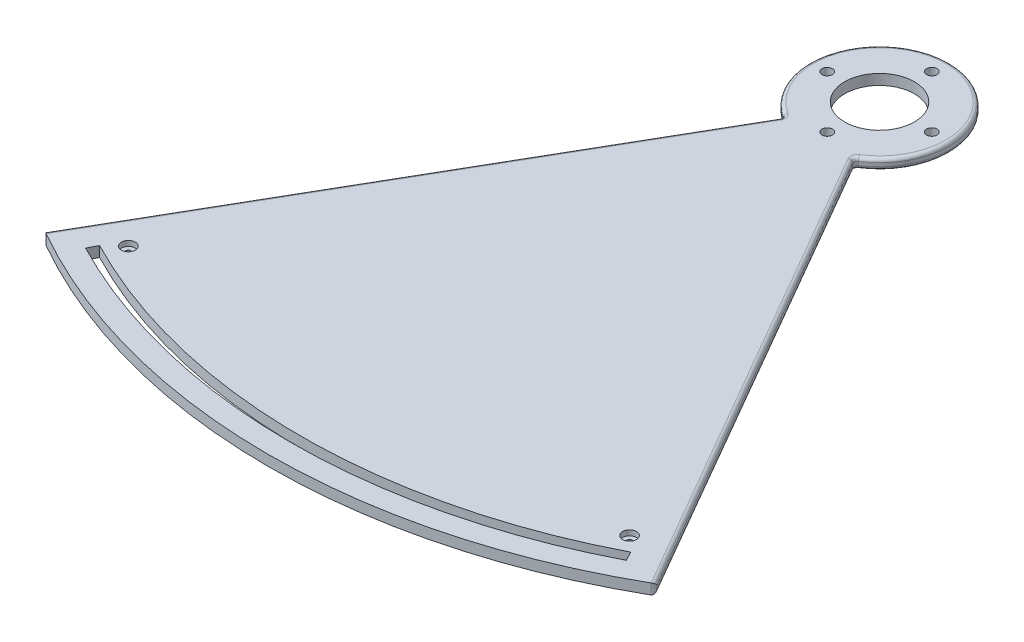
from build123d import *

# Parameters (mm, degrees)
SKETCH_1_R           = 10
SKETCH_1_R_2         = 1.5
EXTRUDE_1_DEPTH      = 3
SKETCH_1_6_W         = 90
SKETCH_1_6_H         = 60
CUT_EXTRUDE_8_DEPTH  = 1.2
SKETCH_1_7_W         = 60
SKETCH_1_7_H         = 90
CUT_EXTRUDE_10_DEPTH = 1.2
FILLET_1_R           = 1
CUT_EXTRUDE_16_DEPTH = 3
SKETCH_16_R          = 2
SKETCH_16_R_2        = 0.75
CUT_EXTRUDE_17_DEPTH = 1.5
SKETCH_16_2_R        = 0.75
CUT_EXTRUDE_18_DEPTH = 3
SKETCH_16_3_R        = 0.75
CUT_EXTRUDE_19_DEPTH = 3


with BuildPart() as part:
    # Sketch 1 → Extrude 1 (new body)
    with BuildSketch(Plane(origin=(0, 0, 0), x_dir=(1, 0, 0), z_dir=(0, 1, 0))):
        with BuildLine():
            ThreePointArc((10, 92.846030188), (0, 130.166538264), (-10, 92.846030188))
            Line((-10, 92.846030188), (-87.624903698, -41.604246949))
            ThreePointArc((-87.624903698, -41.604246949), (0, -65.083269132), (87.624903698, -41.604246949))
            Line((87.624903698, -41.604246949), (10, 92.846030188))
        make_face()
        with Locations((0, 110.166538264)):
            Circle(SKETCH_1_R, mode=Mode.SUBTRACT)
        with Locations((-15, 110.166538264)):
            Circle(SKETCH_1_R_2, mode=Mode.SUBTRACT)
        with Locations((0, 95.166538264)):
            Circle(SKETCH_1_R_2, mode=Mode.SUBTRACT)
        with Locations((0, 125.166538264)):
            Circle(SKETCH_1_R_2, mode=Mode.SUBTRACT)
        with Locations((15, 110.166538264)):
            Circle(SKETCH_1_R_2, mode=Mode.SUBTRACT)
    extrude(amount=EXTRUDE_1_DEPTH)

    # Sketch 1_6 → Cut-Extrude 8 (cut)
    with BuildSketch(Plane(origin=(0, 0, 0), x_dir=(1, 0, 0), z_dir=(0, 1, 0))):
        Rectangle(SKETCH_1_6_W, SKETCH_1_6_H)
    extrude(amount=CUT_EXTRUDE_8_DEPTH, mode=Mode.SUBTRACT)

    # Sketch 1_7 → Cut-Extrude 10 (cut)
    with BuildSketch(Plane(origin=(0, 0, 0), x_dir=(1, 0, 0), z_dir=(0, 1, 0))):
        Rectangle(SKETCH_1_7_W, SKETCH_1_7_H)
    extrude(amount=CUT_EXTRUDE_10_DEPTH, mode=Mode.SUBTRACT)

    # Fillet 1
    fillet_1_edges = [part.edges().sort_by_distance(p)[0] for p in [
        (-48.812451849, 3, -25.620891619),
        (48.812451849, 0, -25.620891619),
        (-48.812451849, 0, -25.620891619),
        (0, 0, -130.166538264),
        (10, 1.5, -92.846030188),
        (-10, 1.5, -92.846030188),
        (48.812451849, 3, -25.620891619),
        (-87.624903698, 1.5, 41.604246949),
        (87.624903698, 1.5, 41.604246949),
        (0, 3, -130.166538264),
    ]]
    fillet(fillet_1_edges, radius=FILLET_1_R)

    # Sketch 12 → Cut-Extrude 16 (cut)
    with BuildSketch(Plane(origin=(0, 0, 0), x_dir=(1, 0, 0), z_dir=(0, 1, 0))):
        with BuildLine():
            Line((-76.171398713, -37.370620692), (-77.547658286, -40.036311895))
            ThreePointArc((-77.547658286, -40.036311895), (0.005617225, -58.873502761), (77.557640639, -40.031157723))
            Line((77.557640639, -40.031157723), (76.181203907, -37.365557993))
            ThreePointArc((76.181203907, -37.365557993), (0.005517534, -55.873502763), (-76.171398713, -37.370620692))
        make_face()
    extrude(amount=CUT_EXTRUDE_16_DEPTH, mode=Mode.SUBTRACT)

    # Sketch 16 → Cut-Extrude 17 (cut)
    with BuildSketch(Plane(origin=(0, 3, 0), x_dir=(1, 0, 0), z_dir=(0, 1, 0))):
        with Locations((71.880670076, -33.396249644)):
            Circle(SKETCH_16_R)
        with Locations((71.880670076, -33.396249644)):
            Circle(SKETCH_16_R_2, mode=Mode.SUBTRACT)
        with Locations((-71.880670076, -33.396249644)):
            Circle(SKETCH_16_R)
        with Locations((-71.880670076, -33.396249644)):
            Circle(SKETCH_16_R_2, mode=Mode.SUBTRACT)
    extrude(amount=-CUT_EXTRUDE_17_DEPTH, mode=Mode.SUBTRACT)

    # Sketch 16_2 → Cut-Extrude 18 (cut)
    with BuildSketch(Plane(origin=(0, 3, 0), x_dir=(1, 0, 0), z_dir=(0, 1, 0))):
        with Locations((71.880670076, -33.396249644)):
            Circle(SKETCH_16_2_R)
    extrude(amount=-CUT_EXTRUDE_18_DEPTH, mode=Mode.SUBTRACT)

    # Sketch 16_3 → Cut-Extrude 19 (cut)
    with BuildSketch(Plane(origin=(0, 3, 0), x_dir=(1, 0, 0), z_dir=(0, 1, 0))):
        with Locations((-71.880670076, -33.396249644)):
            Circle(SKETCH_16_3_R)
    extrude(amount=-CUT_EXTRUDE_19_DEPTH, mode=Mode.SUBTRACT)


solid = part.part
